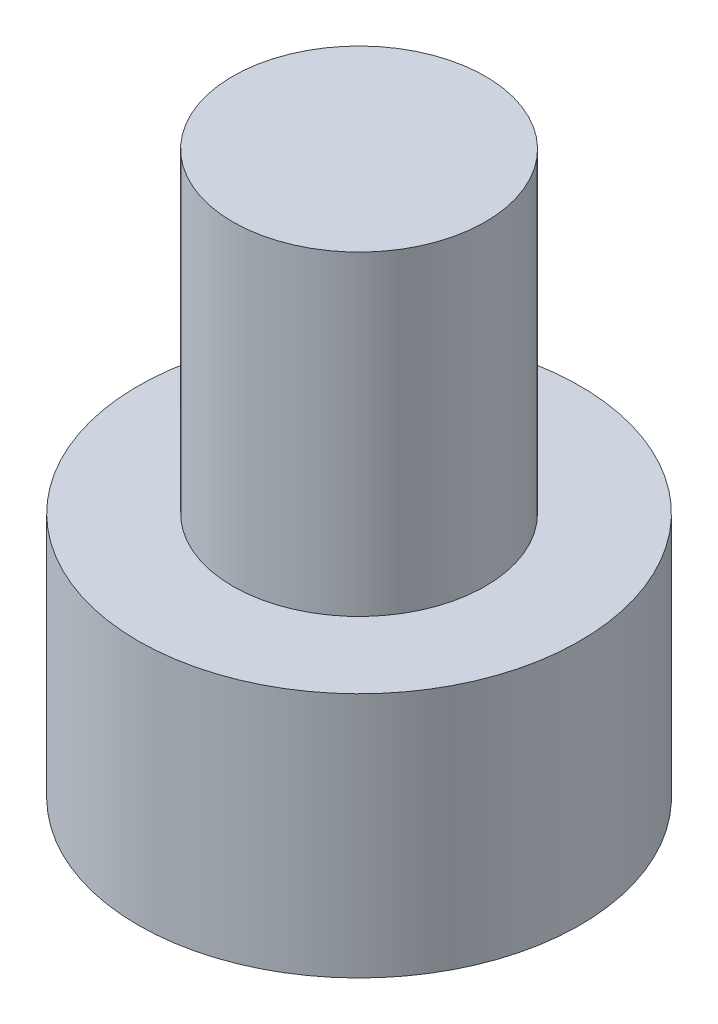
from build123d import *

# Parameters (mm, degrees)
SKETCH_1_R          = 3.5
EXTRUDE_1_DEPTH     = 3.9
SKETCH_2_R          = 2
EXTRUDE_2_DEPTH     = 5
CUT_EXTRUDE_1_DEPTH = 2.4


with BuildPart() as part:
    # 草图1 → 凸台-拉伸1 (new body)
    with BuildSketch(Plane(origin=(0, 0, 0), x_dir=(1, 0, 0), z_dir=(0, 1, 0))):
        Circle(SKETCH_1_R)
    extrude(amount=EXTRUDE_1_DEPTH)

    # 草图2 → 凸台-拉伸2 (add)
    with BuildSketch(Plane(origin=(0, 3.9, 0), x_dir=(1, 0, 0), z_dir=(0, 1, 0))):
        Circle(SKETCH_2_R)
    extrude(amount=EXTRUDE_2_DEPTH)

    # 草图3 → 切除-拉伸1 (cut)
    with BuildSketch(Plane.XZ):
        Polygon((1.725, 0), (0.8625, 1.493893822), (-0.8625, 1.493893822), (-1.725, 0), (-0.8625, -1.493893822), (0.8625, -1.493893822), align=None)
    extrude(amount=-CUT_EXTRUDE_1_DEPTH, mode=Mode.SUBTRACT)


solid = part.part
